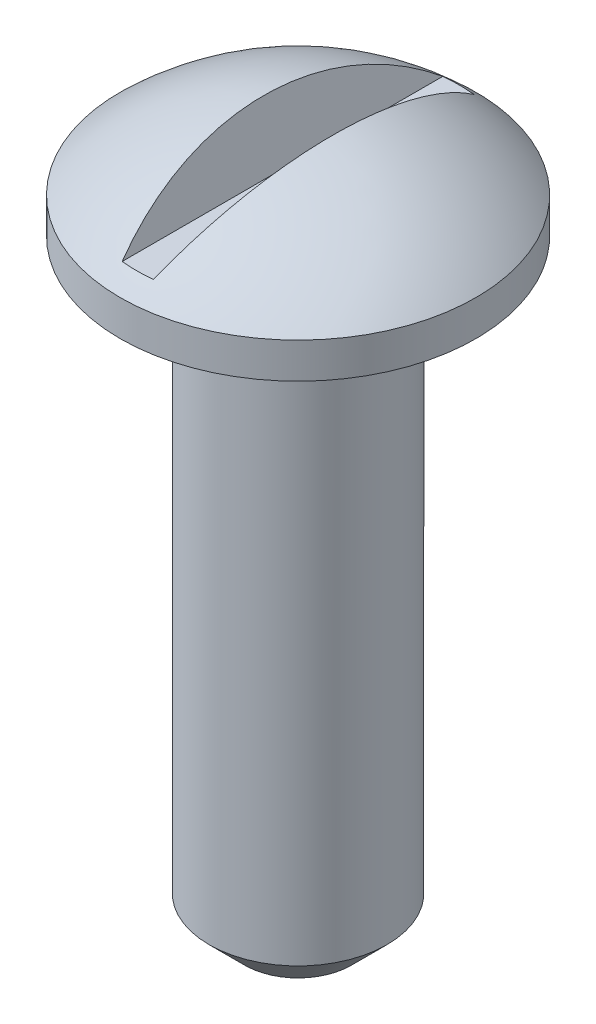
from build123d import *

# Parameters (mm, degrees)
DOME1_FACE_RADIUS       = 12.7
DOME1_HEIGHT            = 5.08
CUT_EXTRUDE1_DEPTH      = 13.7
CUT_EXTRUDE1_DEPTH_BACK = 13.7
CHAMFER1_SIZE           = 2.54


with BuildPart() as part:
    # Sketch1 → Revolve1 (revolve)
    with BuildSketch(Plane.XY):
        Polygon((0, 0), (-6.35, 0), (-6.35, 43.18), (-12.7, 43.18), (-12.7, 45.72), (0, 45.72), align=None)
    revolve(axis=Axis((0, 0, 0), (0, -1, 0)))

    # Dome1: a dome of height H over a round flat face of radius A is a cap of a sphere of radius (A * A + H * H) / (2 * H)
    dome1_r = (DOME1_FACE_RADIUS * DOME1_FACE_RADIUS + DOME1_HEIGHT * DOME1_HEIGHT) / (2 * DOME1_HEIGHT)
    dome1_base = Plane((0, 45.72, 0), z_dir=(0, 1, 0))
    with Locations(dome1_base.offset(DOME1_HEIGHT - dome1_r)):
        dome1_ball = Sphere(dome1_r, mode=Mode.PRIVATE)
    add(split(dome1_ball, bisect_by=dome1_base, keep=Keep.TOP, mode=Mode.PRIVATE))

    # Sketch2 → Cut-Extrude1 (cut, two sides)
    with BuildSketch(Plane.XY) as cut_extrude1_sk:
        Polygon((-40.521693109, 159.90682702), (-2.459280697, 50.635045574), (-1.11246074, 46.768516717), (1.11246074, 46.768516717), (2.459280697, 50.635045574), (40.521693109, 159.90682702), (40.521693109, 391.329120321), (-40.521693109, 391.329120321), align=None)
    extrude(amount=CUT_EXTRUDE1_DEPTH, mode=Mode.SUBTRACT)
    extrude(cut_extrude1_sk.sketch, amount=-CUT_EXTRUDE1_DEPTH_BACK, mode=Mode.SUBTRACT)

    # Chamfer1
    chamfer1_edges = [part.edges().sort_by_distance(p)[0] for p in [
        (6.35, 0, 0),
    ]]
    chamfer(chamfer1_edges, length=CHAMFER1_SIZE)


solid = part.part
